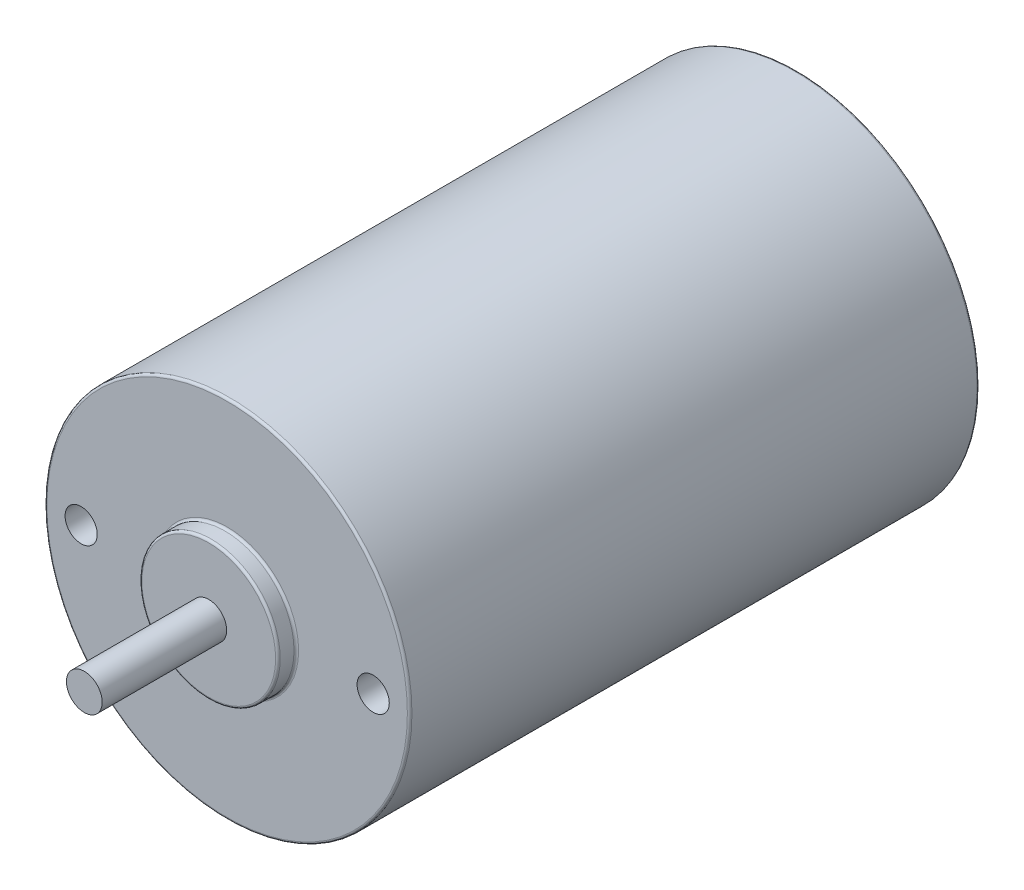
from build123d import *

# Parameters (mm, degrees)
SKETCH4_R             = 1.555
SHAFT_DEPTH           = 37.2
FILLET1_R             = 0.2
SKETCH6_R             = 1.4
F_6_32_THREADED_DEPTH = 5


with BuildPart() as part:
    # Sketch2 → body (revolve)
    with BuildSketch(Plane(origin=(0, 0, 0), x_dir=(1, 0, 0), z_dir=(0, 1, 0))):
        Polygon((1.55, -26.375), (1.55, 26.375), (6.015, 26.375), (6.015, 24.775), (15.875, 24.775), (15.875, -24.775), (6.015, -24.775), (6.015, -26.375), align=None)
    revolve(axis=Axis((0, 0, 0), (0, 0, -1)))

    # Sketch4 → shaft (add)
    with BuildSketch(Plane.XY):
        Circle(SKETCH4_R)
    extrude(amount=SHAFT_DEPTH)

    # Fillet1
    fillet1_edges = [part.edges().sort_by_distance(p)[0] for p in [
        (-6.015, 0, 26.375),
        (-6.015, 0, 24.775),
        (-15.875, 0, 24.775),
        (-15.875, 0, -24.775),
        (-6.015, 0, -24.775),
        (-6.015, 0, -26.375),
    ]]
    fillet(fillet1_edges, radius=FILLET1_R)

    # Sketch6 → #6-32 threaded (cut)
    with BuildSketch(Plane.XY.offset(24.775)):
        with Locations((-12.7, 0)):
            Circle(SKETCH6_R)
        with Locations((12.7, 0)):
            Circle(SKETCH6_R)
    extrude(amount=-F_6_32_THREADED_DEPTH, mode=Mode.SUBTRACT)


solid = part.part
